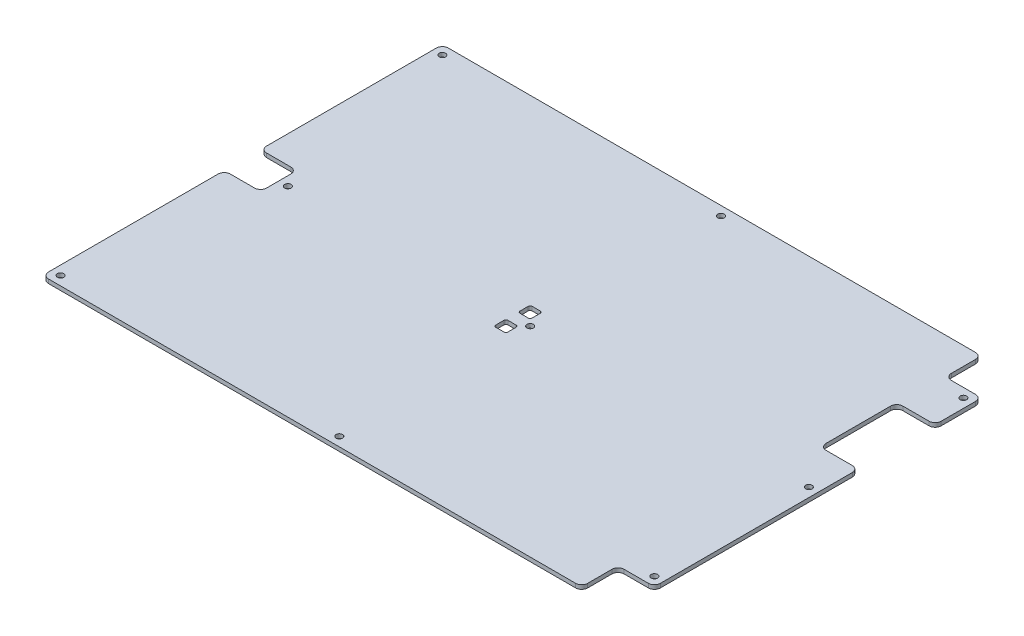
from build123d import *

# Parameters (mm, degrees)
CROQUIS1_R               = 1.6
SALIENTE_EXTRUIR1_DEPTH  = 2
REDONDEO1_R              = 3
CROQUIS3_W               = 19
CROQUIS3_H               = 38
SORTIDA_CABLE_LLIT_DEPTH = 3
REDONDEO3_R              = 3
CROQUIS4_W               = 6
CROQUIS4_H               = 6
FORAT_TERMISTOR_DEPTH    = 3
REDONDEO4_R              = 1


with BuildPart() as part:
    # Croquis1 → Saliente-Extruir1 (new body)
    with BuildSketch(Plane(origin=(0, 2, 0), x_dir=(1, 0, 0), z_dir=(0, 1, 0))):
        Polygon((0, 198), (0, 108), (18, 108), (18, 90), (0, 90), (0, 0), (267, 0), (267, 18), (285, 18), (285, 180), (267, 180), (267, 198), align=None)
        with Locations((142.5, 193.5)):
            Circle(CROQUIS1_R, mode=Mode.SUBTRACT)
        with Locations((4.5, 193.5)):
            Circle(CROQUIS1_R, mode=Mode.SUBTRACT)
        with Locations((280.5, 22.5)):
            Circle(CROQUIS1_R, mode=Mode.SUBTRACT)
        with Locations((280.5, 175.5)):
            Circle(CROQUIS1_R, mode=Mode.SUBTRACT)
        with Locations((280.5, 99)):
            Circle(CROQUIS1_R, mode=Mode.SUBTRACT)
        with Locations((142.5, 4.5)):
            Circle(CROQUIS1_R, mode=Mode.SUBTRACT)
        with Locations((4.5, 4.5)):
            Circle(CROQUIS1_R, mode=Mode.SUBTRACT)
        with Locations((142.5, 99)):
            Circle(CROQUIS1_R, mode=Mode.SUBTRACT)
        with Locations((22.5, 99)):
            Circle(CROQUIS1_R, mode=Mode.SUBTRACT)
    extrude(amount=-SALIENTE_EXTRUIR1_DEPTH)

    # Redondeo1
    redondeo1_edges = [part.edges().sort_by_distance(p)[0] for p in [
        (267, 1, -198),
        (267, 1, -180),
        (285, 1, -180),
        (285, 1, -18),
        (267, 1, -18),
        (267, 1, 0),
        (0, 1, 0),
        (0, 1, -90),
        (18, 1, -90),
        (18, 1, -108),
        (0, 1, -108),
        (0, 1, -198),
    ]]
    fillet(redondeo1_edges, radius=REDONDEO1_R)

    # Croquis3 → Sortida cable llit (cut, through all)
    with BuildSketch(Plane(origin=(0, 2, 0), x_dir=(1, 0, 0), z_dir=(0, 1, 0))):
        with Locations((275.5, 138)):
            Rectangle(CROQUIS3_W, CROQUIS3_H)
    extrude(amount=-SORTIDA_CABLE_LLIT_DEPTH, mode=Mode.SUBTRACT)

    # Redondeo3
    redondeo3_edges = [part.edges().sort_by_distance(p)[0] for p in [
        (285, 1, -157),
        (285, 1, -119),
        (266, 1, -119),
        (266, 1, -157),
    ]]
    fillet(redondeo3_edges, radius=REDONDEO3_R)

    # Croquis4 → Forat termistor (cut, through all)
    with BuildSketch(Plane.XZ):
        with Locations((136.5, -93)):
            Rectangle(CROQUIS4_W, CROQUIS4_H)
        with Locations((136.5, -105)):
            Rectangle(CROQUIS4_W, CROQUIS4_H)
    extrude(amount=-FORAT_TERMISTOR_DEPTH, mode=Mode.SUBTRACT)

    # Redondeo4
    redondeo4_edges = [part.edges().sort_by_distance(p)[0] for p in [
        (133.5, 1, -96),
        (133.5, 1, -90),
        (139.5, 1, -90),
        (139.5, 1, -96),
        (139.5, 1, -108),
        (133.5, 1, -108),
        (133.5, 1, -102),
        (139.5, 1, -102),
    ]]
    fillet(redondeo4_edges, radius=REDONDEO4_R)


solid = part.part
